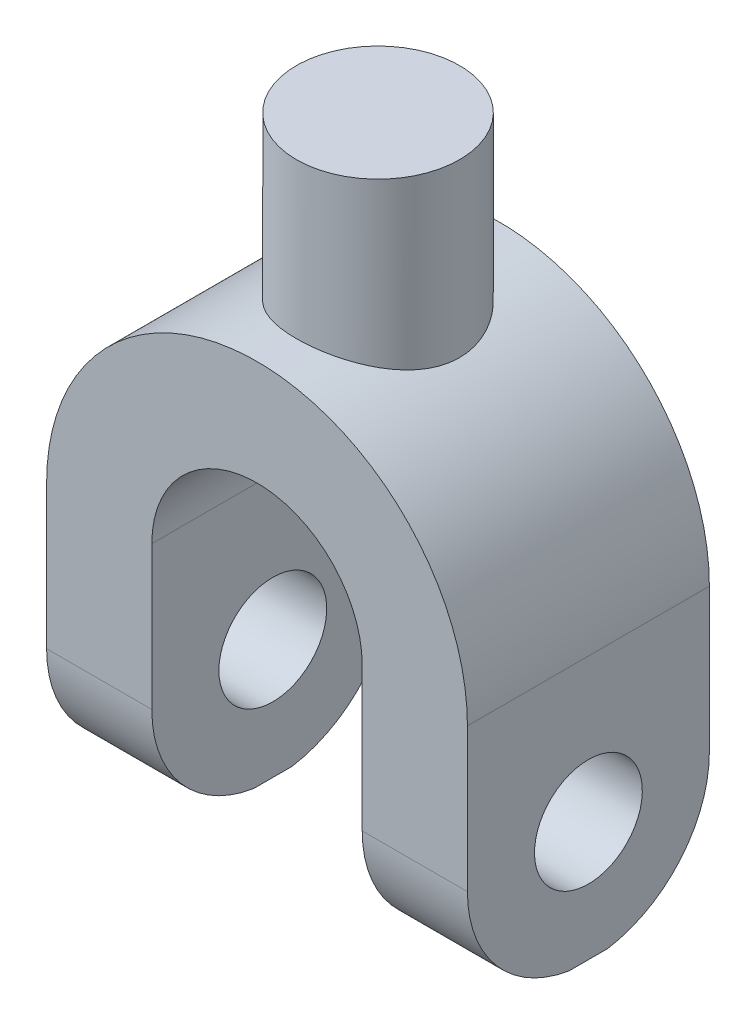
from build123d import *

# Parameters (mm, degrees)
BOSS_EXTRUDE1_DEPTH = 29.21
CUT_EXTRUDE1_DEPTH  = 143.460247374


with BuildPart() as part:
    # Sketch1 → Boss-Extrude1 (new, symmetric)
    with BuildSketch(Plane.XY):
        with BuildLine():
            ThreePointArc((-152.609053498, 7.264609053), (-101.809053498, 58.064609053), (-51.009053498, 7.264609053))
            Line((-51.009053498, 7.264609053), (-51.009053498, -56.235390947))
            Line((-51.009053498, -56.235390947), (-76.409053498, -56.235390947))
            Line((-76.409053498, -56.235390947), (-76.409053498, 7.264609053))
            ThreePointArc((-76.409053498, 7.264609053), (-101.809053498, 32.664609053), (-127.209053498, 7.264609053))
            Line((-127.209053498, 7.264609053), (-127.209053498, -56.235390947))
            Line((-127.209053498, -56.235390947), (-152.609053498, -56.235390947))
            Line((-152.609053498, -56.235390947), (-152.609053498, 7.264609053))
        make_face()
    extrude(amount=BOSS_EXTRUDE1_DEPTH, both=True)

    # Sketch1_4 → Revolve1 (revolve)
    with BuildSketch(Plane.XY, mode=Mode.PRIVATE) as revolve1_sk:
        with BuildLine():
            Line((-121.502148415, 95.494177501), (-121.502148415, 54.092186533))
            ThreePointArc((-121.502148415, 54.092186533), (-111.853929407, 57.061601613), (-101.809053498, 58.064609053))
            Line((-101.809053498, 58.064609053), (-101.809053498, 95.494177501))
            Line((-101.809053498, 95.494177501), (-121.502148415, 95.494177501))
        make_face()
    revolve(revolve1_sk.sketch.rotate(Axis((-101.809053498, 95.494177501, 0), (0, -1, 0)), 270), axis=Axis((-101.809053498, 95.494177501, 0), (0, -1, 0)))

    # Sketch3 → Cut-Extrude1 (cut, through all)
    with BuildSketch(Plane(origin=(-51.009053498, 0, 0), x_dir=(0, 0, -1), z_dir=(1, 0, 0))):
        with BuildLine():
            ThreePointArc((-13.016901543, -27.398347302), (0, -40.415248845), (13.016901543, -27.398347302))
            Line((13.016901543, -27.398347302), (-13.016901543, -27.398347302))
        make_face()
        with BuildLine():
            Line((-13.016901543, -27.398347302), (13.016901543, -27.398347302))
            ThreePointArc((13.016901543, -27.398347302), (0, -14.381445758), (-13.016901543, -27.398347302))
        make_face()
        with BuildLine():
            ThreePointArc((-4.652850075, -56.235390947), (-22.238860702, -46.336593647), (-29.21, -27.398347302))
            Line((-29.21, -27.398347302), (-29.21, -56.235390947))
            Line((-29.21, -56.235390947), (-4.652850075, -56.235390947))
        make_face()
        with BuildLine():
            Line((29.21, -56.235390947), (29.21, -27.398347302))
            ThreePointArc((29.21, -27.398347302), (22.238860702, -46.336593647), (4.652850075, -56.235390947))
            Line((4.652850075, -56.235390947), (29.21, -56.235390947))
        make_face()
    extrude(amount=-CUT_EXTRUDE1_DEPTH, mode=Mode.SUBTRACT)


solid = part.part
